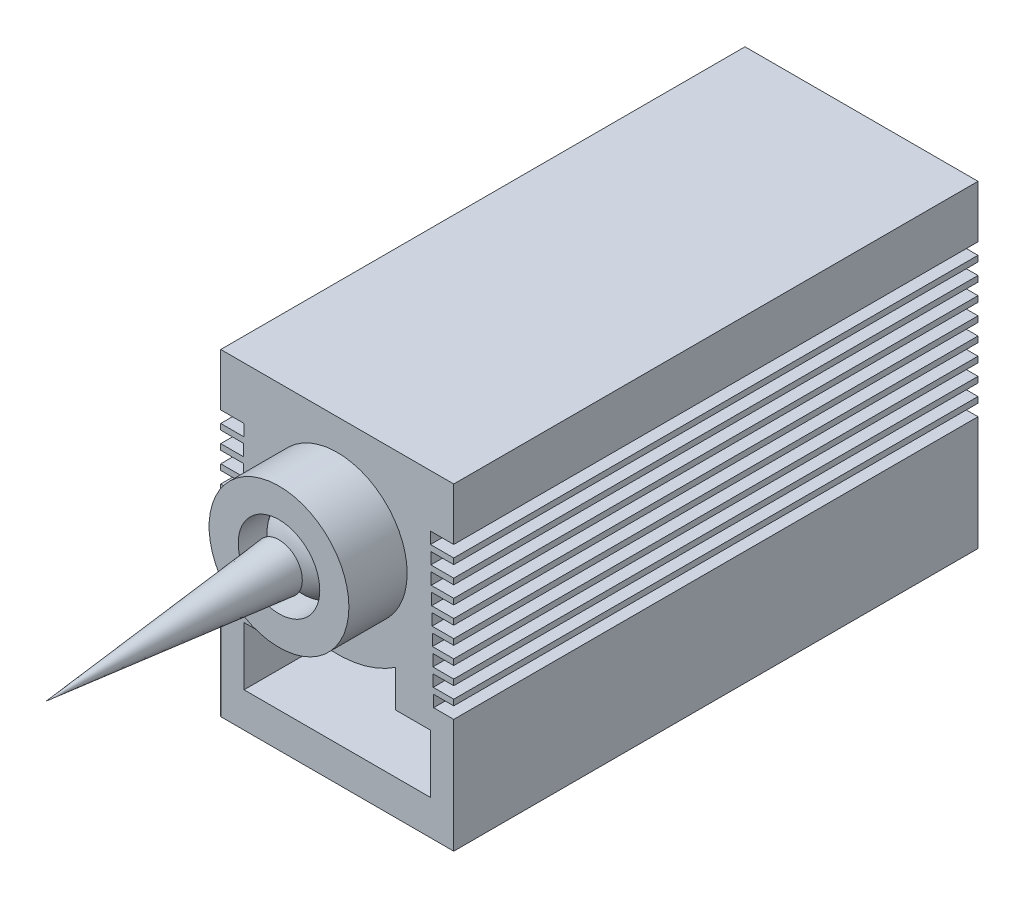
from build123d import *

# Parameters (mm, degrees)
CROQUIS1_W              = 20
CROQUIS1_H              = 27.3
SALIENTE_EXTRUIR1_DEPTH = 45
CROQUIS3_R              = 6
SALIENTE_EXTRUIR2_DEPTH = 5
CORTAR_EXTRUIR1_DEPTH   = 49.076215533
CROQUIS5_R              = 3.5
CORTAR_EXTRUIR2_DEPTH   = 3
C_PULA1_FACE_RADIUS     = 3.5
C_PULA1_HEIGHT          = 2
CROQUIS6_W              = 4
CROQUIS6_H              = 1
CORTAR_EXTRUIR3_DEPTH   = 49.076215533
CROQUIS7_R              = 6.35
CORTAR_EXTRUIR4_DEPTH   = 3


with BuildPart() as part:
    # Croquis1 → Saliente-Extruir1 (new body)
    with BuildSketch(Plane.XY):
        Rectangle(CROQUIS1_W, CROQUIS1_H)
    extrude(amount=SALIENTE_EXTRUIR1_DEPTH)

    # Croquis3 → Saliente-Extruir2 (add)
    with BuildSketch(Plane.XY.offset(45)):
        with Locations((0, 5)):
            Circle(CROQUIS3_R)
    extrude(amount=SALIENTE_EXTRUIR2_DEPTH)

    # Croquis4 → Cortar-Extruir1 (cut, through all)
    with BuildSketch(Plane.XY.offset(45)):
        with BuildLine():
            Line((-5, -5.65), (-8, -5.65))
            Line((-8, -5.65), (-8, -10.65))
            Line((-8, -10.65), (8, -10.65))
            Line((8, -10.65), (8, -5.65))
            Line((8, -5.65), (5, -5.65))
            Line((5, -5.65), (5, -2.483314774))
            ThreePointArc((5, -2.483314774), (0, -4), (-5, -2.483314774))
            Line((-5, -2.483314774), (-5, -5.65))
        make_face()
    extrude(amount=-CORTAR_EXTRUIR1_DEPTH, mode=Mode.SUBTRACT)

    # Croquis5 → Cortar-Extruir2 (cut)
    with BuildSketch(Plane.XY.offset(50)):
        with Locations((0, 5)):
            Circle(CROQUIS5_R)
    extrude(amount=-CORTAR_EXTRUIR2_DEPTH, mode=Mode.SUBTRACT)

    # Cúpula1: an elliptical dome of height H over a round flat face of radius A is half a spheroid: the quarter ellipse of half axes A and H revolved about the face's axis
    with BuildSketch(Plane((0, 5, 47), x_dir=(0, 1, 0), z_dir=(1, 0, 0)), mode=Mode.PRIVATE) as c_pula1_quarter:
        Ellipse(C_PULA1_FACE_RADIUS, C_PULA1_HEIGHT)
        Rectangle(C_PULA1_FACE_RADIUS, C_PULA1_HEIGHT, align=(Align.MIN, Align.MIN), mode=Mode.INTERSECT)
    revolve(c_pula1_quarter.sketch, axis=Axis((0, 5, 47), (0, 0, 1)))

    # Croquis6 → Cortar-Extruir3 (cut, through all)
    with BuildSketch(Plane.XY.offset(45)):
        with Locations((-10, 8.65)):
            Rectangle(CROQUIS6_W, CROQUIS6_H)
        with Locations((-10.033808809, 7.15038106)):
            Rectangle(CROQUIS6_W, CROQUIS6_H)
        with Locations((-10.067617617, 5.65076212)):
            Rectangle(CROQUIS6_W, CROQUIS6_H)
        with Locations((-10.101426426, 4.151143181)):
            Rectangle(CROQUIS6_W, CROQUIS6_H)
        with Locations((-10.135235234, 2.651524241)):
            Rectangle(CROQUIS6_W, CROQUIS6_H)
        with Locations((-10.169044043, 1.151905301)):
            Rectangle(CROQUIS6_W, CROQUIS6_H)
        with Locations((-10.202852851, -0.347713639)):
            Rectangle(CROQUIS6_W, CROQUIS6_H)
        with Locations((-10.23666166, -1.847332578)):
            Rectangle(CROQUIS6_W, CROQUIS6_H)
        with Locations((-10.270470468, -3.346951518)):
            Rectangle(CROQUIS6_W, CROQUIS6_H)
        with Locations((10.23666166, -1.847332578)):
            Rectangle(CROQUIS6_W, CROQUIS6_H)
        with Locations((10.202852851, -0.347713639)):
            Rectangle(CROQUIS6_W, CROQUIS6_H)
        with Locations((10.169044043, 1.151905301)):
            Rectangle(CROQUIS6_W, CROQUIS6_H)
        with Locations((10.135235234, 2.651524241)):
            Rectangle(CROQUIS6_W, CROQUIS6_H)
        with Locations((10.101426426, 4.151143181)):
            Rectangle(CROQUIS6_W, CROQUIS6_H)
        with Locations((10.067617617, 5.65076212)):
            Rectangle(CROQUIS6_W, CROQUIS6_H)
        with Locations((10.033808809, 7.15038106)):
            Rectangle(CROQUIS6_W, CROQUIS6_H)
        with Locations((10, 8.65)):
            Rectangle(CROQUIS6_W, CROQUIS6_H)
        with Locations((10.270470468, -3.346951518)):
            Rectangle(CROQUIS6_W, CROQUIS6_H)
    extrude(amount=-CORTAR_EXTRUIR3_DEPTH, mode=Mode.SUBTRACT)

    # Croquis7 → Cortar-Extruir4 (cut)
    with BuildSketch(Plane(origin=(0, 0, 0), x_dir=(-1, 0, 0), z_dir=(0, 0, -1))):
        with Locations((0, 3.3)):
            Circle(CROQUIS7_R)
    extrude(amount=-CORTAR_EXTRUIR4_DEPTH, mode=Mode.SUBTRACT)


with BuildPart() as body_2:
    # Croquis8 → Revolución1 (revolve)
    with BuildSketch(Plane(origin=(0, 0, 0), x_dir=(0, 0, -1), z_dir=(1, 0, 0))):
        Polygon((-70, 5), (-50, 7), (-50, 5), align=None)
    revolve(axis=Axis((0, 5, 50), (0, 0, 1)))


solid = Compound([part.part, body_2.part])
